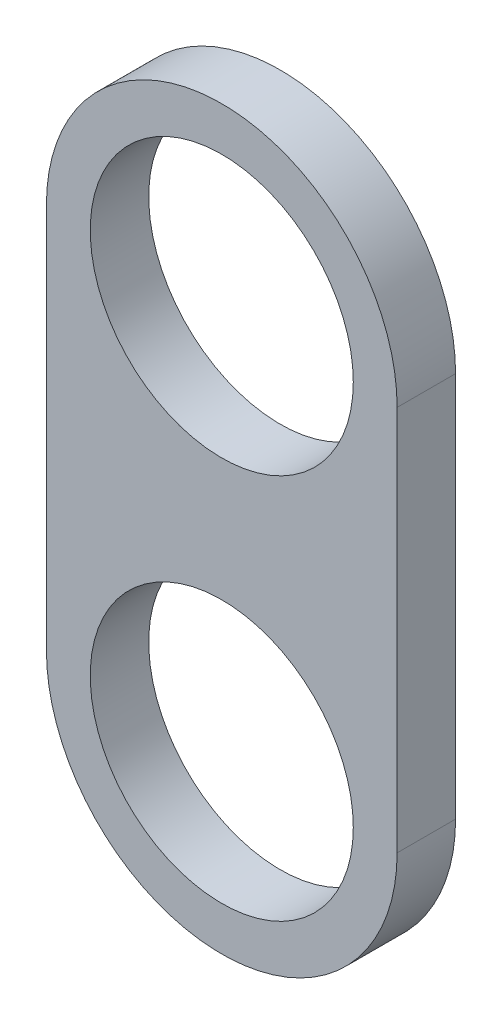
from build123d import *

# Parameters (mm, degrees)
BOSS_EXTRUDE1_DEPTH        = 6.35
F_1_1_DIAMETER_HOLE1_D     = 28.575
F_1_1_DIAMETER_HOLE1_DEPTH = 25.4
F_1_1_DIAMETER_HOLE1_TIP   = 8.584796094


with BuildPart() as part:
    # Sketch1 → Boss-Extrude1 (new body)
    with BuildSketch(Plane.XY):
        with BuildLine():
            Line((-19.05, 0), (-19.05, 41.91))
            ThreePointArc((-19.05, 41.91), (0, 60.96), (19.05, 41.91))
            Line((19.05, 41.91), (19.05, 0))
            ThreePointArc((19.05, 0), (0, -19.05), (-19.05, 0))
        make_face()
    extrude(amount=BOSS_EXTRUDE1_DEPTH)

    # 1 (1) Diameter Hole1
    with Locations(Plane.XY.offset(6.35)):
        with Locations((0, 41.91), (0, 0)):
            Hole(F_1_1_DIAMETER_HOLE1_D / 2, depth=F_1_1_DIAMETER_HOLE1_DEPTH)
            with Locations((0, 0, -(F_1_1_DIAMETER_HOLE1_DEPTH + F_1_1_DIAMETER_HOLE1_TIP / 2))):  # 118° drill point
                Cone(0, F_1_1_DIAMETER_HOLE1_D / 2, F_1_1_DIAMETER_HOLE1_TIP, mode=Mode.SUBTRACT)


solid = part.part
